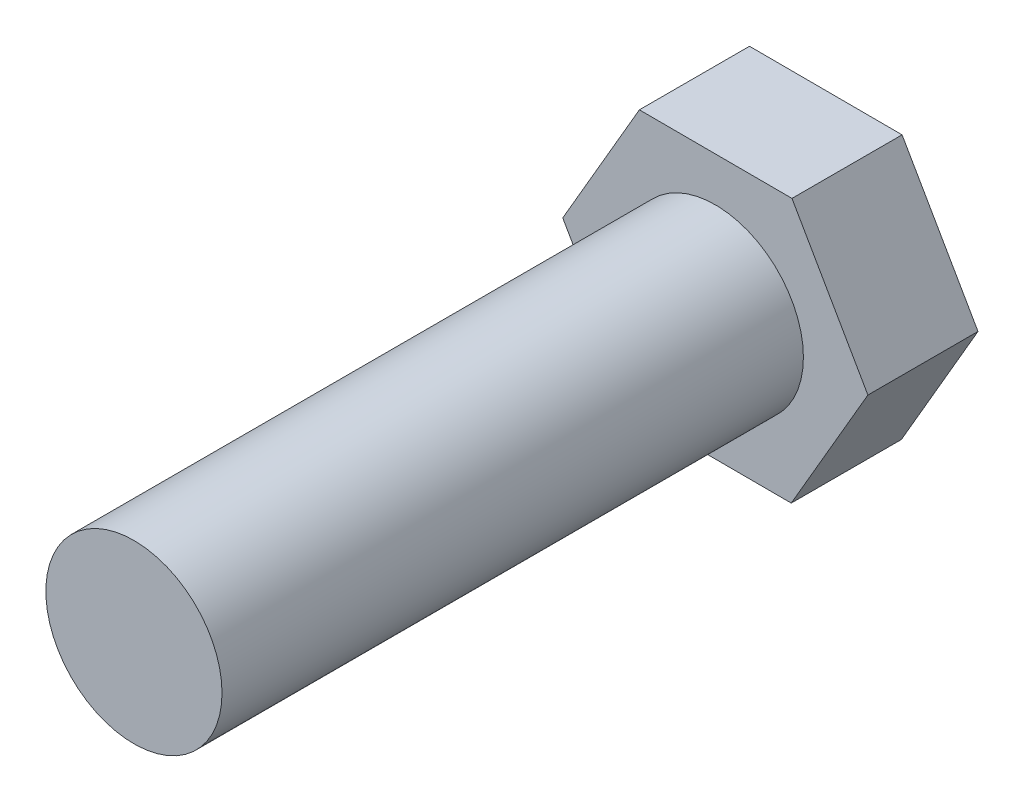
from build123d import *

# Parameters (mm, degrees)
BOSS_EXTRUDE1_DEPTH = 7.9375
SKETCH2_R           = 6.35
BOSS_EXTRUDE2_DEPTH = 41.91


with BuildPart() as part:
    # Sketch1 → Boss-Extrude1 (new body)
    with BuildSketch(Plane.XY):
        Polygon((5.473160021, -9.54002198), (10.998481398, -0.030115373), (5.525321377, 9.509906607), (-5.473160021, 9.54002198), (-10.998481398, 0.030115373), (-5.525321377, -9.509906607), align=None)
    extrude(amount=BOSS_EXTRUDE1_DEPTH)

    # Sketch2 → Boss-Extrude2 (add)
    with BuildSketch(Plane.XY.offset(7.9375)):
        Circle(SKETCH2_R)
    extrude(amount=BOSS_EXTRUDE2_DEPTH)


solid = part.part
